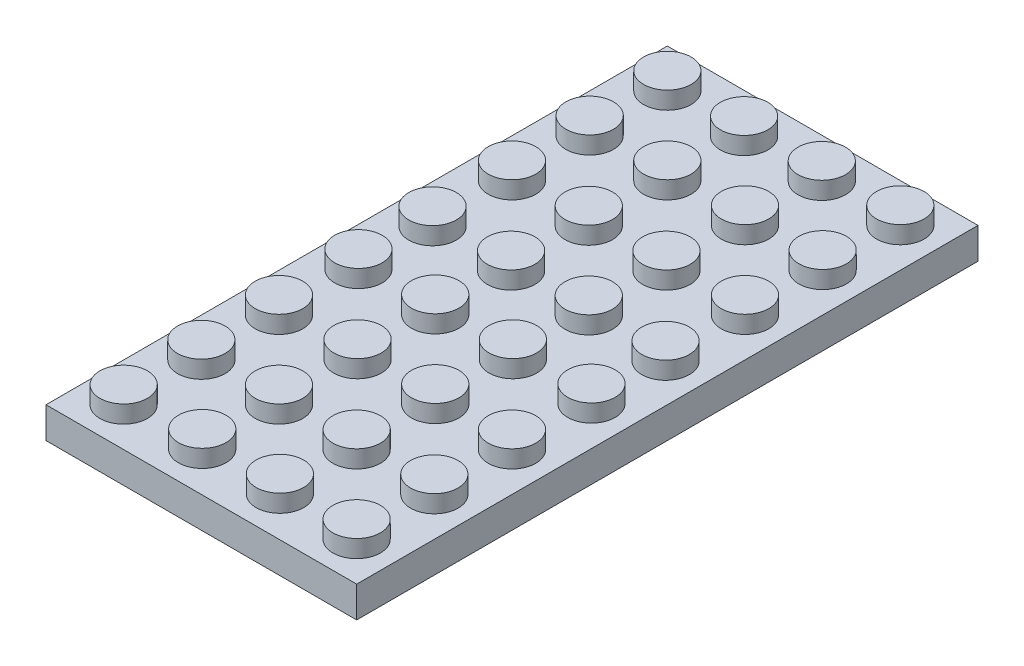
from build123d import *

# Parameters (mm, degrees)
SKETCH3_W           = 32
SKETCH3_H           = 64
BOSS_EXTRUDE2_DEPTH = 3.2
SKETCH4_R           = 2.45
BOSS_EXTRUDE3_DEPTH = 1.8
SKETCH5_W           = 29
SKETCH5_H           = 61
CUT_EXTRUDE1_DEPTH  = 2
SKETCH6_R           = 3.2
BOSS_EXTRUDE4_DEPTH = 2
SKETCH7_R           = 2.5
SKETCH7_R_2         = 2.513496794
CUT_EXTRUDE2_DEPTH  = 2


with BuildPart() as part:
    # Sketch3 → Boss-Extrude2 (new body)
    with BuildSketch(Plane(origin=(0, 0, 0), x_dir=(1, 0, 0), z_dir=(0, 1, 0))):
        Rectangle(SKETCH3_W, SKETCH3_H)
    extrude(amount=BOSS_EXTRUDE2_DEPTH)

    # Sketch4 → Boss-Extrude3 (add)
    with BuildSketch(Plane(origin=(0, 3.2, 0), x_dir=(1, 0, 0), z_dir=(0, 1, 0))):
        with Locations((-12, 28)):
            Circle(SKETCH4_R)
        with Locations((-4, 27.908524957)):
            Circle(SKETCH4_R)
        with Locations((4, 27.908524957)):
            Circle(SKETCH4_R)
        with Locations((12, 28)):
            Circle(SKETCH4_R)
        with Locations((12, 20)):
            Circle(SKETCH4_R)
        with Locations((4, 20)):
            Circle(SKETCH4_R)
        with Locations((-4, 20)):
            Circle(SKETCH4_R)
        with Locations((-12, 20)):
            Circle(SKETCH4_R)
        with Locations((12, 12)):
            Circle(SKETCH4_R)
        with Locations((12, 3.817049914)):
            Circle(SKETCH4_R)
        with Locations((4, 3.908524957)):
            Circle(SKETCH4_R)
        with Locations((4, 11.908524957)):
            Circle(SKETCH4_R)
        with Locations((-4, 11.908524957)):
            Circle(SKETCH4_R)
        with Locations((-4, 3.908524957)):
            Circle(SKETCH4_R)
        with Locations((-12, 3.817049914)):
            Circle(SKETCH4_R)
        with Locations((-12, 12)):
            Circle(SKETCH4_R)
        with Locations((4, -27.908524957)):
            Circle(SKETCH4_R)
        with Locations((12, -28)):
            Circle(SKETCH4_R)
        with Locations((12, -20)):
            Circle(SKETCH4_R)
        with Locations((4, -20)):
            Circle(SKETCH4_R)
        with Locations((4, -11.908524957)):
            Circle(SKETCH4_R)
        with Locations((12, -12)):
            Circle(SKETCH4_R)
        with Locations((12, -3.817049914)):
            Circle(SKETCH4_R)
        with Locations((4, -3.908524957)):
            Circle(SKETCH4_R)
        with Locations((-4, -3.908524957)):
            Circle(SKETCH4_R)
        with Locations((-4, -11.908524957)):
            Circle(SKETCH4_R)
        with Locations((-4, -20)):
            Circle(SKETCH4_R)
        with Locations((-4, -27.908524957)):
            Circle(SKETCH4_R)
        with Locations((-12, -28)):
            Circle(SKETCH4_R)
        with Locations((-12, -20)):
            Circle(SKETCH4_R)
        with Locations((-12, -12)):
            Circle(SKETCH4_R)
        with Locations((-12, -3.817049914)):
            Circle(SKETCH4_R)
    extrude(amount=BOSS_EXTRUDE3_DEPTH)

    # Sketch5 → Cut-Extrude1 (cut)
    with BuildSketch(Plane.XZ):
        Rectangle(SKETCH5_W, SKETCH5_H)
    extrude(amount=-CUT_EXTRUDE1_DEPTH, mode=Mode.SUBTRACT)

    # Sketch6 → Boss-Extrude4 (add)
    with BuildSketch(Plane.XZ.offset(-2)):
        with Locations((-8, 24)):
            Circle(SKETCH6_R)
        with Locations((0, 24)):
            Circle(SKETCH6_R)
        with Locations((8, 24)):
            Circle(SKETCH6_R)
        with Locations((8, 16)):
            Circle(SKETCH6_R)
        with Locations((0, 16)):
            Circle(SKETCH6_R)
        with Locations((-8, 16)):
            Circle(SKETCH6_R)
        with Locations((0, 8)):
            Circle(SKETCH6_R)
        with Locations((8, 8)):
            Circle(SKETCH6_R)
        with Locations((8, 0)):
            Circle(SKETCH6_R)
        Circle(SKETCH6_R)
        with Locations((-8, 0)):
            Circle(SKETCH6_R)
        with Locations((-8, 8)):
            Circle(SKETCH6_R)
        with Locations((8, -24)):
            Circle(SKETCH6_R)
        with Locations((8, -16)):
            Circle(SKETCH6_R)
        with Locations((8, -8)):
            Circle(SKETCH6_R)
        with Locations((0, -8)):
            Circle(SKETCH6_R)
        with Locations((0, -16)):
            Circle(SKETCH6_R)
        with Locations((0, -24)):
            Circle(SKETCH6_R)
        with Locations((-8, -24)):
            Circle(SKETCH6_R)
        with Locations((-8, -16)):
            Circle(SKETCH6_R)
        with Locations((-8, -8)):
            Circle(SKETCH6_R)
    extrude(amount=BOSS_EXTRUDE4_DEPTH)

    # Sketch7 → Cut-Extrude2 (cut)
    with BuildSketch(Plane.XZ.offset(-2)):
        with Locations((-8, -24)):
            Circle(SKETCH7_R)
        with Locations((0, -24)):
            Circle(SKETCH7_R)
        with Locations((8, -24)):
            Circle(SKETCH7_R_2)
        with Locations((-8, -16)):
            Circle(SKETCH7_R)
        with Locations((0, -16)):
            Circle(SKETCH7_R)
        with Locations((8, -16)):
            Circle(SKETCH7_R)
        with Locations((-8, -8)):
            Circle(SKETCH7_R)
        with Locations((0, -8)):
            Circle(SKETCH7_R)
        with Locations((8, -8)):
            Circle(SKETCH7_R)
        with Locations((-8, 8)):
            Circle(SKETCH7_R)
        with Locations((0, 8)):
            Circle(SKETCH7_R)
        with Locations((8, 8)):
            Circle(SKETCH7_R_2)
        with Locations((8, 0)):
            Circle(SKETCH7_R)
        Circle(SKETCH7_R)
        with Locations((-8, 0)):
            Circle(SKETCH7_R)
        with Locations((0, 16)):
            Circle(SKETCH7_R)
        with Locations((8, 16)):
            Circle(SKETCH7_R)
        with Locations((8, 24)):
            Circle(SKETCH7_R)
        with Locations((0, 24)):
            Circle(SKETCH7_R)
        with Locations((-8, 24)):
            Circle(SKETCH7_R)
        with Locations((-8, 16)):
            Circle(SKETCH7_R)
    extrude(amount=CUT_EXTRUDE2_DEPTH, mode=Mode.SUBTRACT)


solid = part.part
